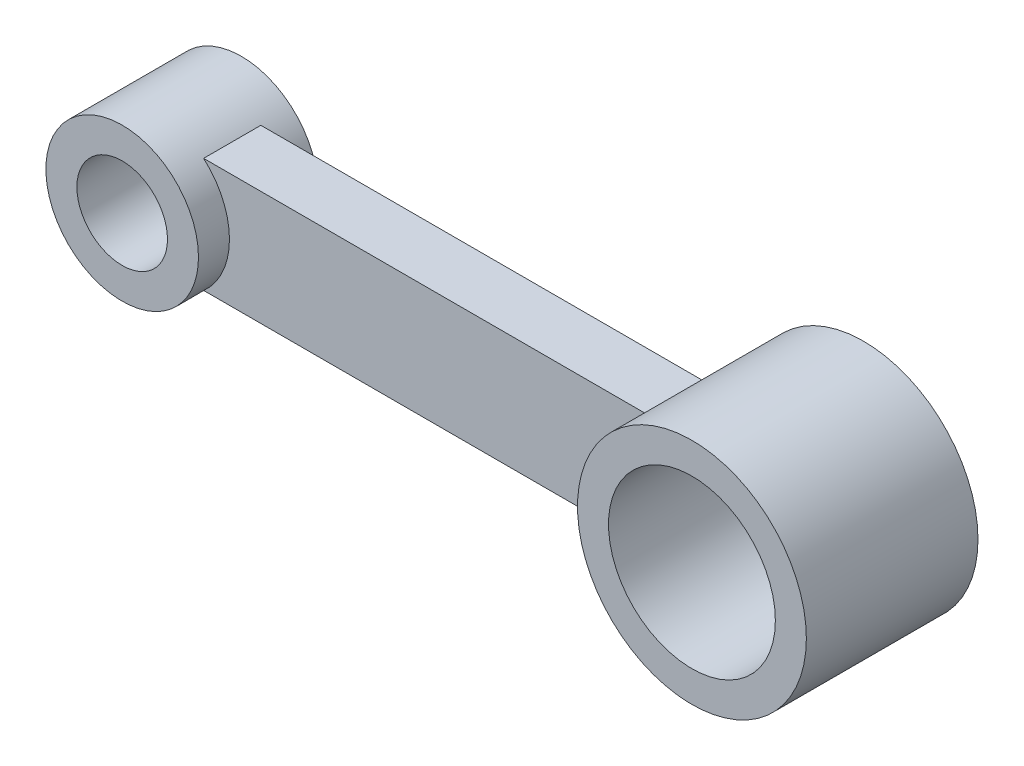
from build123d import *
from build123d.topology import SkipClean

# Parameters (mm, degrees)
SKETCH2_R           = 9.5
SKETCH2_R_2         = 17.5
BOSS_EXTRUDE1_DEPTH = 36
CUT_EXTRUDE1_DEPTH  = 12
CUT_EXTRUDE2_DEPTH  = 12
SKETCH6_R           = 16
SKETCH6_R_2         = 9.5
CUT_EXTRUDE3_DEPTH  = 5.5
SKETCH7_R           = 16
SKETCH7_R_2         = 9.5
CUT_EXTRUDE4_DEPTH  = 5.5
SKETCH8_R           = 24
SKETCH8_R_2         = 17.5
BOSS_EXTRUDE2_DEPTH = 36
SKETCH9_R           = 16
SKETCH9_R_2         = 9.5
BOSS_EXTRUDE4_DEPTH = 25


with BuildPart() as part:
    # Sketch2 → Boss-Extrude1 (new body)
    with BuildSketch(Plane.XY):
        with BuildLine():
            ThreePointArc((10.583005244, 12), (-15.998110701, 0.245873959), (10.209239534, -12.319554705))
            Line((10.209239534, -12.319554705), (10.526232528, -12.049831068))
            ThreePointArc((10.526232528, -12.049831068), (10.554648294, -12.024949039), (10.583005244, -12))
            Line((10.583005244, -12), (104.215390309, -12))
            ThreePointArc((104.215390309, -12), (149, 0), (104.215390309, 12))
            Line((104.215390309, 12), (10.583005244, 12))
        make_face()
        Circle(SKETCH2_R, mode=Mode.SUBTRACT)
        with Locations((125, 0)):
            Circle(SKETCH2_R_2, mode=Mode.SUBTRACT)
    extrude(amount=BOSS_EXTRUDE1_DEPTH)

    # Sketch3 → Cut-Extrude1 (cut)
    with BuildSketch(Plane(origin=(0, 0, 0), x_dir=(-1, 0, 0), z_dir=(0, 0, -1))):
        with BuildLine():
            Line((-104.215390309, 12), (-10.583005244, 12))
            ThreePointArc((-10.583005244, 12), (-15.553567993, 0), (-10.583005244, -12))
            Line((-10.583005244, -12), (-104.215390309, -12))
            ThreePointArc((-104.215390309, -12), (-101.138897743, 0), (-104.215390309, 12))
        make_face()
    extrude(amount=-CUT_EXTRUDE1_DEPTH, mode=Mode.SUBTRACT)

    # Sketch4 → Cut-Extrude2 (cut)
    with BuildSketch(Plane.XY.offset(36)):
        with BuildLine():
            Line((10.583005244, 12), (104.215390309, 12))
            ThreePointArc((104.215390309, 12), (101, 0), (104.215390309, -12))
            Line((104.215390309, -12), (10.367736031, -12.184692887))
            ThreePointArc((10.367736031, -12.184692887), (15.484184535, -0.136930157), (10.583005244, 12))
        make_face()
    extrude(amount=-CUT_EXTRUDE2_DEPTH, mode=Mode.SUBTRACT)

    # Sketch6 → Cut-Extrude3 (cut)
    with BuildSketch(Plane.XY.offset(36)):
        Circle(SKETCH6_R)
        Circle(SKETCH6_R_2, mode=Mode.SUBTRACT)
    extrude(amount=-CUT_EXTRUDE3_DEPTH, mode=Mode.SUBTRACT)

    # Sketch7 → Cut-Extrude4 (cut)
    with BuildSketch(Plane(origin=(0, 0, 0), x_dir=(-1, 0, 0), z_dir=(0, 0, -1))):
        Circle(SKETCH7_R)
        Circle(SKETCH7_R_2, mode=Mode.SUBTRACT)
    extrude(amount=-CUT_EXTRUDE4_DEPTH, mode=Mode.SUBTRACT)

    # Sketch8 → Boss-Extrude2 (add)
    with BuildSketch(Plane(origin=(0, 0, 0), x_dir=(-1, 0, 0), z_dir=(0, 0, -1))):
        with Locations(Location((-125, 0, 0), (0, 0, 180))):
            Circle(SKETCH8_R)
        with Locations(Location((-125, 0, 0), (0, 0, 180))):
            Circle(SKETCH8_R_2, mode=Mode.SUBTRACT)
    extrude(amount=-BOSS_EXTRUDE2_DEPTH)

    # Sketch9 → Boss-Extrude4 (add)
    with SkipClean():  # the faces are left unmerged after this step: merging them gives an invalid solid
        with BuildSketch(Plane(origin=(0, 0, 5.5), x_dir=(-1, 0, 0), z_dir=(0, 0, -1))):
            with Locations(Location((0, 0, 0), (0, 0, 230.351389725))):
                Circle(SKETCH9_R)
            Circle(SKETCH9_R_2, mode=Mode.SUBTRACT)
        extrude(amount=-BOSS_EXTRUDE4_DEPTH)


solid = part.part
